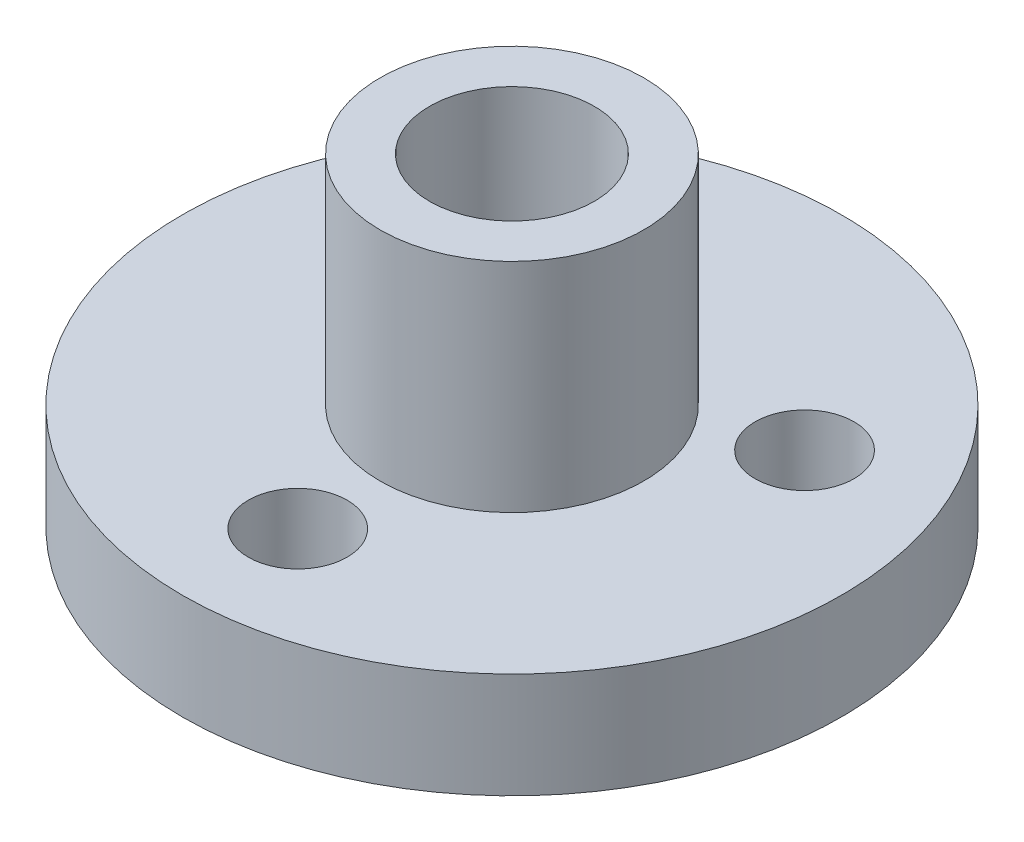
from build123d import *

# Parameters (mm, degrees)
ESBO_O1_R                = 10
ESBO_O1_R_2              = 2.5
RESSALTO_EXTRUS_O1_DEPTH = 3.2
ESBO_O2_R                = 1.5
CORTE_EXTRUS_O1_DEPTH    = 3.2
PADR_OCIRCULAR1_COUNT    = 3
ESBO_O3_R                = 4
ESBO_O3_R_2              = 2.5
RESSALTO_EXTRUS_O2_DEPTH = 6.6


with BuildPart() as part:
    # Esboço1 → Ressalto-extrusão1 (new body)
    with BuildSketch(Plane(origin=(0, 0, 0), x_dir=(1, 0, 0), z_dir=(0, 1, 0))):
        Circle(ESBO_O1_R)
        Circle(ESBO_O1_R_2, mode=Mode.SUBTRACT)
    extrude(amount=RESSALTO_EXTRUS_O1_DEPTH)

    # Esboço2 → Corte-extrusão1 (cut)
    with BuildSketch(Plane.XZ):
        with Locations((0, 6.5)):
            Circle(ESBO_O2_R)
    corte_extrus_o1 = extrude(amount=-CORTE_EXTRUS_O1_DEPTH, mode=Mode.SUBTRACT)

    # PadrãoCircular1: Corte-extrusão1 ×3 about axis
    padr_ocircular1_axis = Axis((0, 0, 0), (0, 1, 0))
    for i in range(1, PADR_OCIRCULAR1_COUNT):
        add(corte_extrus_o1.rotate(padr_ocircular1_axis, i * 360 / PADR_OCIRCULAR1_COUNT), mode=Mode.SUBTRACT)

    # Esboço3 → Ressalto-extrusão2 (add)
    with BuildSketch(Plane(origin=(0, 3.2, 0), x_dir=(1, 0, 0), z_dir=(0, 1, 0))):
        Circle(ESBO_O3_R)
        Circle(ESBO_O3_R_2, mode=Mode.SUBTRACT)
    extrude(amount=RESSALTO_EXTRUS_O2_DEPTH)


solid = part.part
